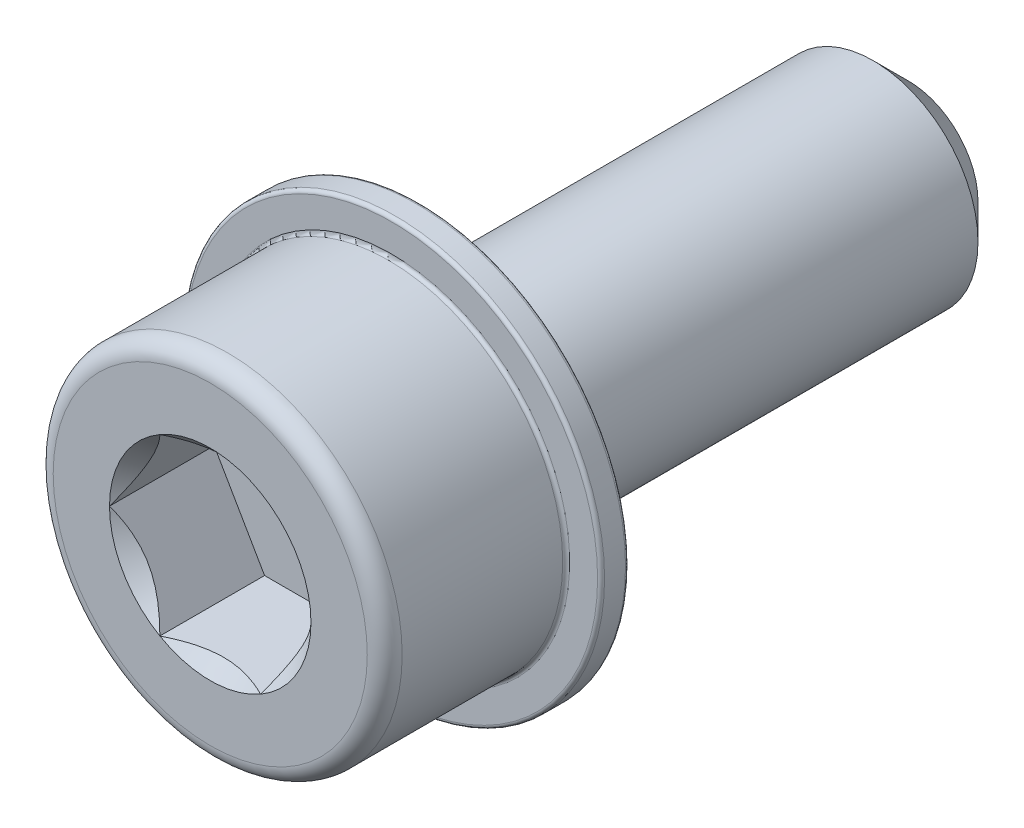
from build123d import *

# Parameters (mm, degrees)
SCHIZZO1_R                   = 3
ESTRUSIONE_ESTRUSIONE1_DEPTH = 14
SMUSSO1_SIZE                 = 1
SCHIZZO6_R                   = 5
ESTRUSIONE_ESTRUSIONE3_DEPTH = 6
TAGLIO_ESTRUSIONE3_DEPTH     = 3
SCHIZZO8_R                   = 2.886751346
TAGLIO_ESTRUSIONE4_DEPTH     = 1
TAGLIO_ESTRUSIONE4_TAPER     = 45
RACCORDO1_R                  = 0.5
SCHIZZO9_R                   = 6
SCHIZZO9_R_2                 = 5
ESTRUSIONE_ESTRUSIONE4_DEPTH = 0.8
RACCORDO3_R                  = 0.1


with BuildPart() as part:
    # Schizzo1 → Estrusione-Estrusione1 (new body)
    with BuildSketch(Plane.XY):
        Circle(SCHIZZO1_R)
    extrude(amount=ESTRUSIONE_ESTRUSIONE1_DEPTH)

    # Smusso1
    smusso1_edges = [part.edges().sort_by_distance(p)[0] for p in [
        (-3, 0, 0),
    ]]
    chamfer(smusso1_edges, length=SMUSSO1_SIZE)

    # Schizzo6 → Estrusione-Estrusione3 (add)
    with BuildSketch(Plane.XY.offset(14)):
        Circle(SCHIZZO6_R)
    extrude(amount=ESTRUSIONE_ESTRUSIONE3_DEPTH)

    # Schizzo7 → Taglio-Estrusione3 (cut)
    with BuildSketch(Plane.XY.offset(20)):
        Polygon((1.443375673, 2.5), (-1.443375673, 2.5), (-2.886751346, 0), (-1.443375673, -2.5), (1.443375673, -2.5), (2.886751346, 0), align=None)
    extrude(amount=-TAGLIO_ESTRUSIONE3_DEPTH, mode=Mode.SUBTRACT)

    # Schizzo8 → Taglio-Estrusione4 (cut)
    with BuildSketch(Plane.XY.offset(20)):
        Circle(SCHIZZO8_R)
    extrude(amount=-TAGLIO_ESTRUSIONE4_DEPTH, taper=TAGLIO_ESTRUSIONE4_TAPER, mode=Mode.SUBTRACT)

    # Raccordo1
    raccordo1_edges = [part.edges().sort_by_distance(p)[0] for p in [
        (-5, 0, 20),
    ]]
    fillet(raccordo1_edges, radius=RACCORDO1_R)

    # Schizzo9 → Estrusione-Estrusione4 (add)
    with BuildSketch(Plane(origin=(0, 0, 14), x_dir=(-1, 0, 0), z_dir=(0, 0, -1))):
        Circle(SCHIZZO9_R)
        Circle(SCHIZZO9_R_2, mode=Mode.SUBTRACT)
    extrude(amount=-ESTRUSIONE_ESTRUSIONE4_DEPTH)

    # Raccordo3
    raccordo3_edges = [part.edges().sort_by_distance(p)[0] for p in [
        (-5, 0, 14.8),
        (6, 0, 14.8),
        (6, 0, 14),
    ]]
    fillet(raccordo3_edges, radius=RACCORDO3_R)


solid = part.part
